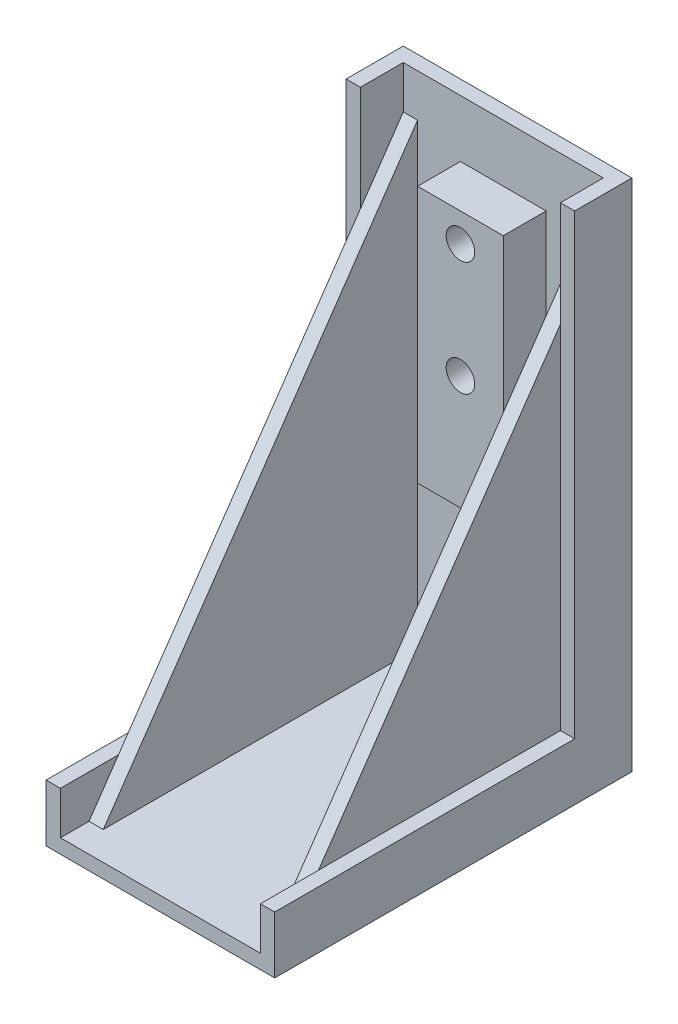
from build123d import *

# Parameters (mm, degrees)
SKETCH1_W               = 20
SKETCH1_H               = 31.25
BOSS_EXTRUDE1_DEPTH     = 2.5
CUT_EXTRUDE1_DEPTH      = 3.75
BOSS_EXTRUDE2_DEPTH     = 40
SKETCH4_W               = 1.25
SKETCH4_H               = 27.5
BOSS_EXTRUDE3_DEPTH     = 40
CUT_EXTRUDE5_DEPTH      = 16.25
CUT_EXTRUDE5_DEPTH_BACK = 1.25
SKETCH10_R              = 1.25
CUT_EXTRUDE6_DEPTH      = 45.75
CUT_EXTRUDE6_DEPTH_BACK = 2.25
SKETCH11_W              = 7.5
SKETCH11_H              = 22.5
BOSS_EXTRUDE4_DEPTH     = 3.75
SKETCH12_R              = 1.25
CUT_EXTRUDE7_DEPTH      = 13.75


with BuildPart() as part:
    # Sketch1 → Boss-Extrude1 (new body, symmetric)
    with BuildSketch(Plane(origin=(0, 0, 0), x_dir=(1, 0, 0), z_dir=(0, 1, 0))):
        with Locations((0, 1.875)):
            Rectangle(SKETCH1_W, SKETCH1_H)
    extrude(amount=BOSS_EXTRUDE1_DEPTH, both=True)

    # Sketch2 → Cut-Extrude1 (cut)
    with BuildSketch(Plane(origin=(0, 2.5, 0), x_dir=(1, 0, 0), z_dir=(0, 1, 0))):
        Polygon((-8.75, -12.5), (-8.75, -13.75), (8.75, -13.75), (8.75, -12.5), (8.75, 16.25), (-8.75, 16.25), align=None)
    extrude(amount=-CUT_EXTRUDE1_DEPTH, mode=Mode.SUBTRACT)

    # Sketch3 → Boss-Extrude2 (add)
    with BuildSketch(Plane(origin=(0, 2.5, 0), x_dir=(1, 0, 0), z_dir=(0, 1, 0))):
        Polygon((-8.75, 16.25), (-8.736970705, 16.25), (8.75, 16.25), (8.75, 12.5), (10, 12.5), (10, 17.5), (-8.732627572, 17.5), (-10, 17.5), (-10, 12.5), (-8.75, 12.5), align=None)
    extrude(amount=BOSS_EXTRUDE2_DEPTH)

    # Sketch4 → Boss-Extrude3 (add)
    with BuildSketch(Plane(origin=(0, -1.25, 0), x_dir=(1, 0, 0), z_dir=(0, 1, 0))):
        with Locations((8.125, 2.5)):
            Rectangle(SKETCH4_W, SKETCH4_H)
        with Locations((-8.125, 2.5)):
            Rectangle(SKETCH4_W, SKETCH4_H)
    extrude(amount=BOSS_EXTRUDE3_DEPTH)

    # Sketch7 → Cut-Extrude5 (cut, two sides)
    with BuildSketch(Plane.ZY.offset(-7.5)) as cut_extrude5_sk:
        Polygon((-16.25, 38.75), (11.25, 38.75), (11.25, -1.25), align=None)
    extrude(amount=CUT_EXTRUDE5_DEPTH, mode=Mode.SUBTRACT)
    extrude(cut_extrude5_sk.sketch, amount=-CUT_EXTRUDE5_DEPTH_BACK, mode=Mode.SUBTRACT)

    # Sketch10 → Cut-Extrude6 (cut, two sides)
    with BuildSketch(Plane.XY.offset(-16.25)) as cut_extrude6_sk:
        with Locations((0, 35)):
            Circle(SKETCH10_R)
        with Locations((0, 25)):
            Circle(SKETCH10_R)
    extrude(amount=CUT_EXTRUDE6_DEPTH, mode=Mode.SUBTRACT)
    extrude(cut_extrude6_sk.sketch, amount=-CUT_EXTRUDE6_DEPTH_BACK, mode=Mode.SUBTRACT)

    # Sketch11 → Boss-Extrude4 (add)
    with BuildSketch(Plane.XY.offset(-16.25)):
        with Locations((0, 26.25)):
            Rectangle(SKETCH11_W, SKETCH11_H)
    extrude(amount=BOSS_EXTRUDE4_DEPTH)

    # Sketch12 → Cut-Extrude7 (cut)
    with BuildSketch(Plane(origin=(0, 0, -17.5), x_dir=(-1, 0, 0), z_dir=(0, 0, -1))):
        with Locations((0, 35)):
            Circle(SKETCH12_R)
        with Locations((0, 25)):
            Circle(SKETCH12_R)
    extrude(amount=-CUT_EXTRUDE7_DEPTH, mode=Mode.SUBTRACT)


solid = part.part
